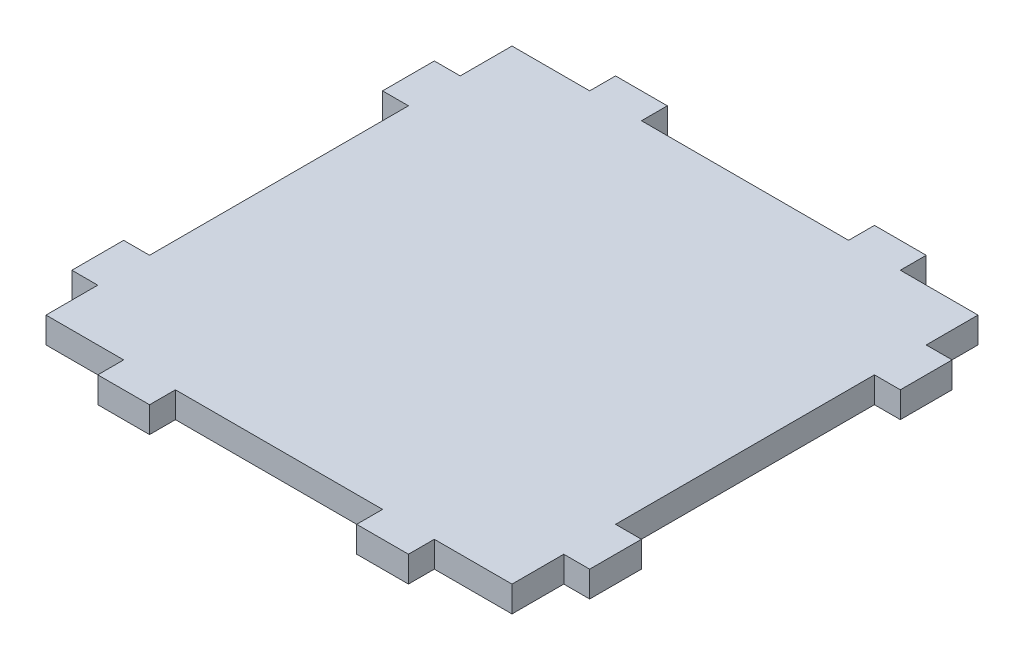
from build123d import *

# Parameters (mm, degrees)
BOSS_EXTRUDE1_DEPTH = 5


with BuildPart() as part:
    # Sketch1 → Boss-Extrude1 (new body)
    with BuildSketch(Plane(origin=(0, 0, 0), x_dir=(1, 0, 0), z_dir=(0, 1, 0))):
        Polygon((-45, 45), (-30, 45), (-30, 50), (-20, 50), (-20, 45), (20, 45), (20, 50), (30, 50), (30, 45), (45, 45), (45, 35), (50, 35), (50, 25), (45, 25), (45, -25), (50, -25), (50, -35), (45, -35), (45, -45), (30, -45), (30, -50), (20, -50), (20, -45), (-20, -45), (-20, -50), (-30, -50), (-30, -45), (-45, -45), (-45, -35), (-50, -35), (-50, -25), (-45, -25), (-45, 25), (-50, 25), (-50, 35), (-45, 35), align=None)
    extrude(amount=BOSS_EXTRUDE1_DEPTH)


solid = part.part
